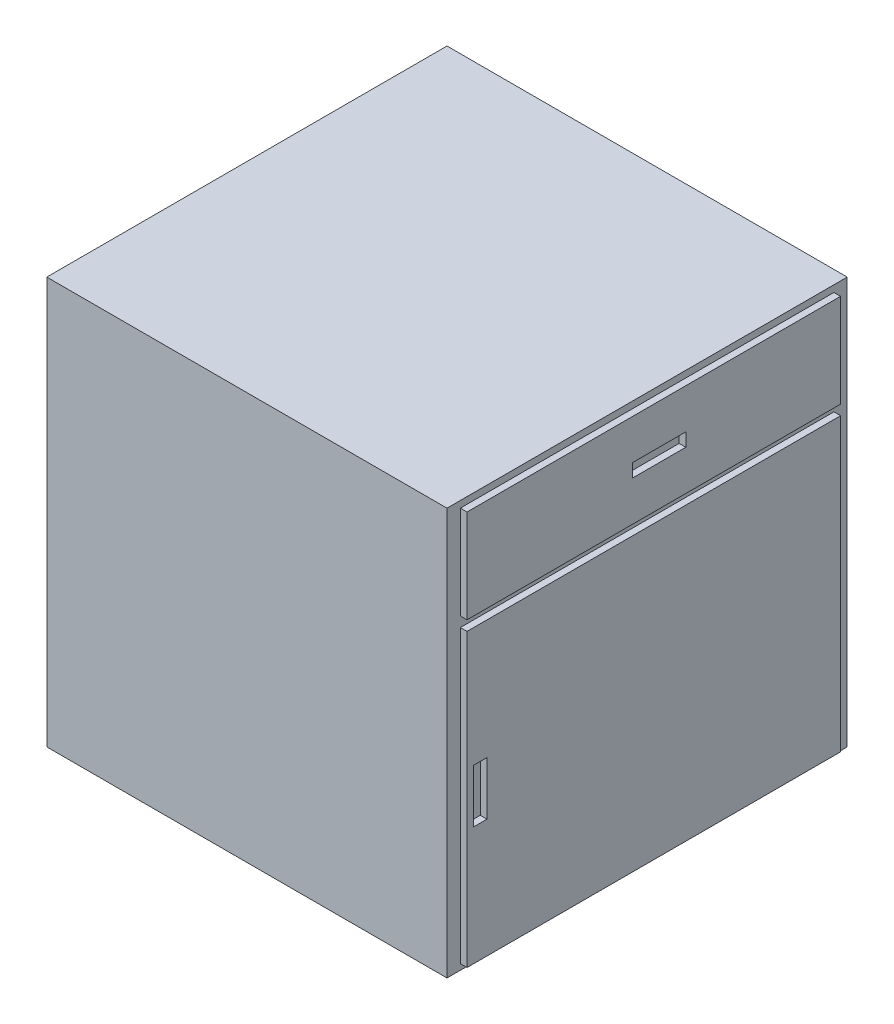
from build123d import *

# Parameters (mm, degrees)
SKETCH1_W           = 600
SKETCH1_H           = 610
BOSS_EXTRUDE1_DEPTH = 600
SKETCH2_W           = 560
SKETCH2_H           = 140
SKETCH2_W_2         = 80
SKETCH2_H_2         = 20
SKETCH2_H_3         = 436.439883301
SKETCH2_W_3         = 20
SKETCH2_H_4         = 80
BOSS_EXTRUDE2_DEPTH = 10


with BuildPart() as part:
    # Sketch1 → Boss-Extrude1 (new body)
    with BuildSketch(Plane.XY):
        with Locations((-300, -305)):
            Rectangle(SKETCH1_W, SKETCH1_H)
    extrude(amount=BOSS_EXTRUDE1_DEPTH)

    # Sketch2 → Boss-Extrude2 (add)
    with BuildSketch(Plane(origin=(0, 0, 0), x_dir=(0, 0, -1), z_dir=(1, 0, 0))):
        with Locations((-300, -79.996604702)):
            Rectangle(SKETCH2_W, SKETCH2_H)
        with Locations((-292, -79.960529666)):
            Rectangle(SKETCH2_W_2, SKETCH2_H_2, mode=Mode.SUBTRACT)
        with Locations((-300, -383.216546353)):
            Rectangle(SKETCH2_W, SKETCH2_H_3)
        with Locations((-560, -383.759018759)):
            Rectangle(SKETCH2_W_3, SKETCH2_H_4, mode=Mode.SUBTRACT)
    extrude(amount=BOSS_EXTRUDE2_DEPTH)


solid = part.part
